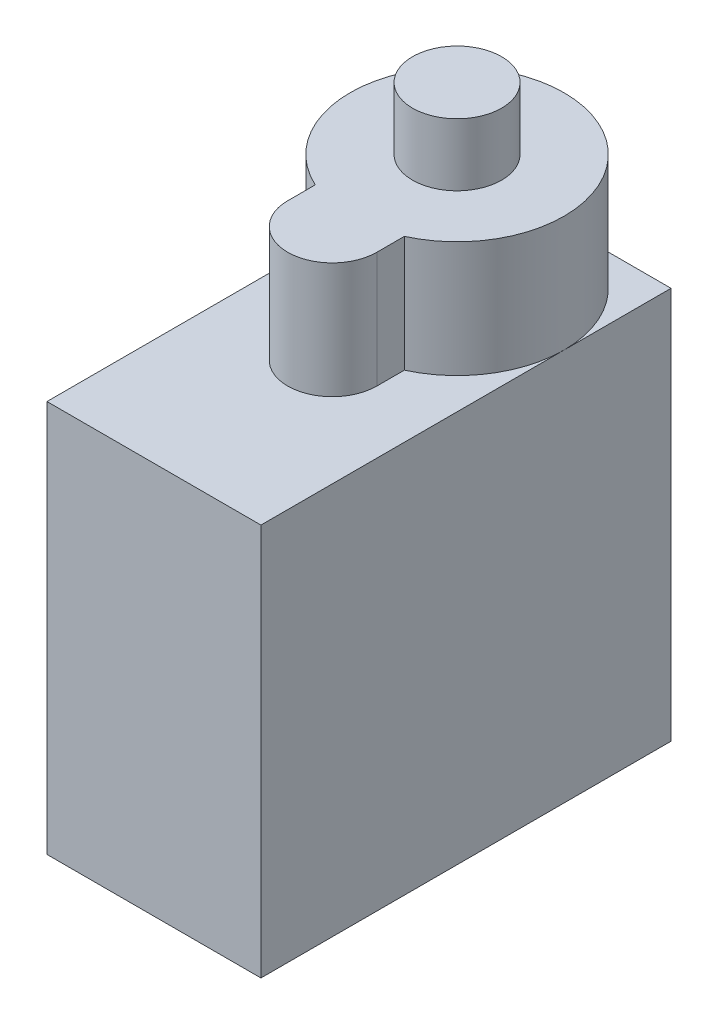
from build123d import *

# Parameters (mm, degrees)
SKETCH4_R           = 2.5
BOSS_EXTRUDE2_DEPTH = 32
BOSS_EXTRUDE3_DEPTH = 28.5
SKETCH1_W           = 12
SKETCH1_H           = 23
BOSS_EXTRUDE4_DEPTH = 22


with BuildPart() as part:
    # Sketch4 → Boss-Extrude2 (new body)
    with BuildSketch(Plane(origin=(0, 0, 0), x_dir=(1, 0, 0), z_dir=(0, 1, 0))):
        with Locations((51.314367453, -99.151596437)):
            Circle(SKETCH4_R)
    extrude(amount=BOSS_EXTRUDE2_DEPTH)

    # Sketch3 → Boss-Extrude3 (add)
    with BuildSketch(Plane(origin=(0, 0, 0), x_dir=(1, 0, 0), z_dir=(0, 1, 0))):
        with BuildLine():
            Line((48.814367453, -106.151596437), (48.814367453, -104.605952495))
            ThreePointArc((48.814367453, -104.605952495), (51.314367453, -93.151596437), (53.814367453, -104.605952495))
            Line((53.814367453, -104.605952495), (53.814367453, -106.151596437))
            ThreePointArc((53.814367453, -106.151596437), (51.314367453, -108.651596437), (48.814367453, -106.151596437))
        make_face()
    extrude(amount=BOSS_EXTRUDE3_DEPTH)

    # Sketch1 → Boss-Extrude4 (add)
    with BuildSketch(Plane(origin=(0, 0, 0), x_dir=(1, 0, 0), z_dir=(0, 1, 0))):
        with Locations((51.314367453, -104.651596437)):
            Rectangle(SKETCH1_W, SKETCH1_H)
    extrude(amount=BOSS_EXTRUDE4_DEPTH)


solid = part.part
